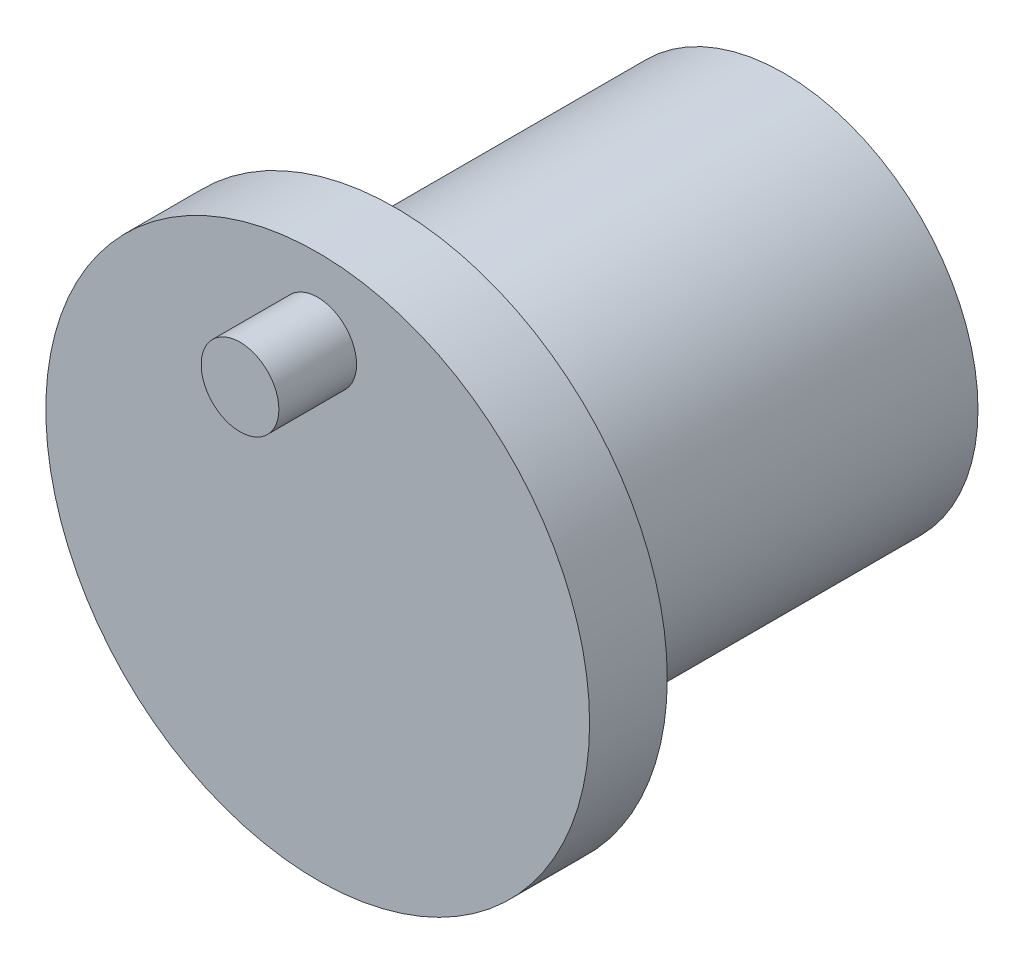
from build123d import *

# Parameters (mm, degrees)
SKETCH1_R           = 7
BOSS_EXTRUDE1_DEPTH = 2
SKETCH2_R           = 1
BOSS_EXTRUDE2_DEPTH = 2
SKETCH3_R           = 5
BOSS_EXTRUDE3_DEPTH = 10


with BuildPart() as part:
    # Sketch1 → Boss-Extrude1 (new body)
    with BuildSketch(Plane.XY):
        Circle(SKETCH1_R)
    extrude(amount=-BOSS_EXTRUDE1_DEPTH)

    # Sketch2 → Boss-Extrude2 (add)
    with BuildSketch(Plane.XY):
        with Locations((0, 5)):
            Circle(SKETCH2_R)
    extrude(amount=BOSS_EXTRUDE2_DEPTH)

    # Sketch3 → Boss-Extrude3 (add)
    with BuildSketch(Plane(origin=(0, 0, -2), x_dir=(-1, 0, 0), z_dir=(0, 0, -1))):
        Circle(SKETCH3_R)
    extrude(amount=BOSS_EXTRUDE3_DEPTH)


solid = part.part
